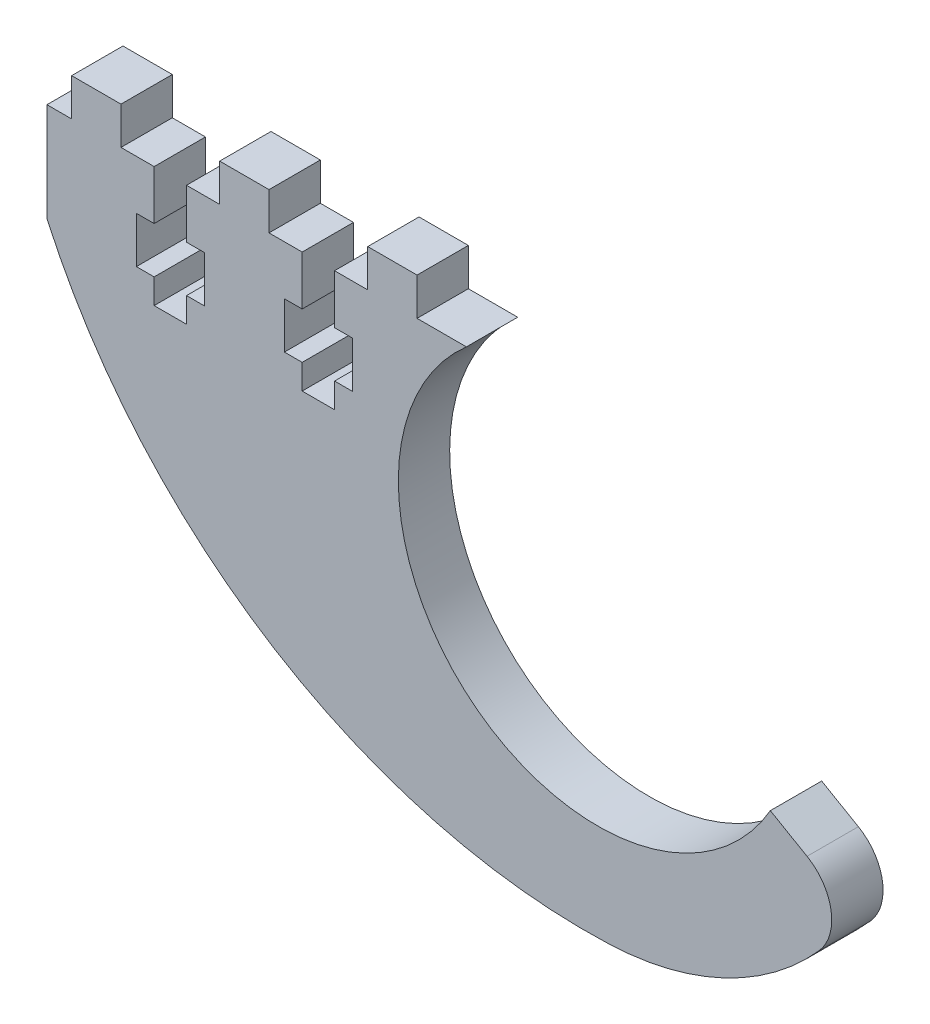
from build123d import *

# Parameters (mm, degrees)
BOSS_EXTRUDE1_DEPTH = 6.604
SKETCH3_W           = 6.35
SKETCH3_H           = 4.826
BOSS_EXTRUDE2_DEPTH = 6.604
CUT_EXTRUDE1_REACH  = 8.604
FILLET1_R           = 6.35


with BuildPart() as part:
    # Sketch1 → Boss-Extrude1 (new body)
    with BuildSketch(Plane.XY):
        with BuildLine():
            Line((-6.35, -5.08), (-53.975, -5.08))
            Line((-53.975, -5.08), (-53.975, -17.78))
            ThreePointArc((-53.975, -17.78), (-24.613831362, -51.146124163), (18.36841389, -62.455547599))
            ThreePointArc((18.36841389, -62.455547599), (36.58027843, -57.005297746), (49.891818948, -43.434))
            Line((49.891818948, -43.434), (39.113266772, -37.211))
            ThreePointArc((39.113266772, -37.211), (0.611966481, -44.206961223), (0, -5.08))
            Line((0, -5.08), (-6.35, -5.08))
        make_face()
    extrude(amount=BOSS_EXTRUDE1_DEPTH)

    # Sketch3 → Boss-Extrude2 (add)
    with BuildSketch(Plane.XY.offset(6.604)):
        with Locations((-47.625, -2.667)):
            Rectangle(SKETCH3_W, SKETCH3_H)
        with Locations((-28.575, -2.667)):
            Rectangle(SKETCH3_W, SKETCH3_H)
        with Locations((-9.525, -2.667)):
            Rectangle(SKETCH3_W, SKETCH3_H)
    extrude(amount=-BOSS_EXTRUDE2_DEPTH)

    # Sketch4 → Cut-Extrude1 (cut, up to next)
    with BuildSketch(Plane.XY.offset(6.604), mode=Mode.PRIVATE) as cut_extrude1_sk1:
        Polygon((-40.1828, -5.08), (-40.1828, -11.43), (-42.4688, -11.43), (-42.4688, -17.3736), (-40.1828, -17.3736), (-40.1828, -20.574), (-36.0172, -20.574), (-36.0172, -17.3736), (-33.7312, -17.3736), (-33.7312, -11.43), (-36.0172, -11.43), (-36.0172, -5.08), align=None)
    cut_extrude1_tool1 = extrude(cut_extrude1_sk1.sketch, amount=-CUT_EXTRUDE1_REACH, mode=Mode.PRIVATE) & part.part
    add(cut_extrude1_tool1.solids().sort_by_distance((-38.1, -13.293591, 6.604))[0], mode=Mode.SUBTRACT)
    # Sketch4 → Cut-Extrude1 (cut, up to next)
    with BuildSketch(Plane.XY.offset(6.604), mode=Mode.PRIVATE) as cut_extrude1_sk2:
        Polygon((-21.1328, -11.43), (-23.4188, -11.43), (-23.4188, -17.3736), (-21.1328, -17.3736), (-21.1328, -20.574), (-16.9672, -20.574), (-16.9672, -17.3736), (-14.6812, -17.3736), (-14.6812, -11.43), (-16.9672, -11.43), (-16.9672, -5.08), (-21.1328, -5.08), align=None)
    cut_extrude1_tool2 = extrude(cut_extrude1_sk2.sketch, amount=-CUT_EXTRUDE1_REACH, mode=Mode.PRIVATE) & part.part
    add(cut_extrude1_tool2.solids().sort_by_distance((-19.05, -13.293591, 6.604))[0], mode=Mode.SUBTRACT)

    # Fillet1
    fillet1_edges = [part.edges().sort_by_distance(p)[0] for p in [
        (49.891818948, -43.434, 3.302),
    ]]
    fillet(fillet1_edges, radius=FILLET1_R)


solid = part.part
